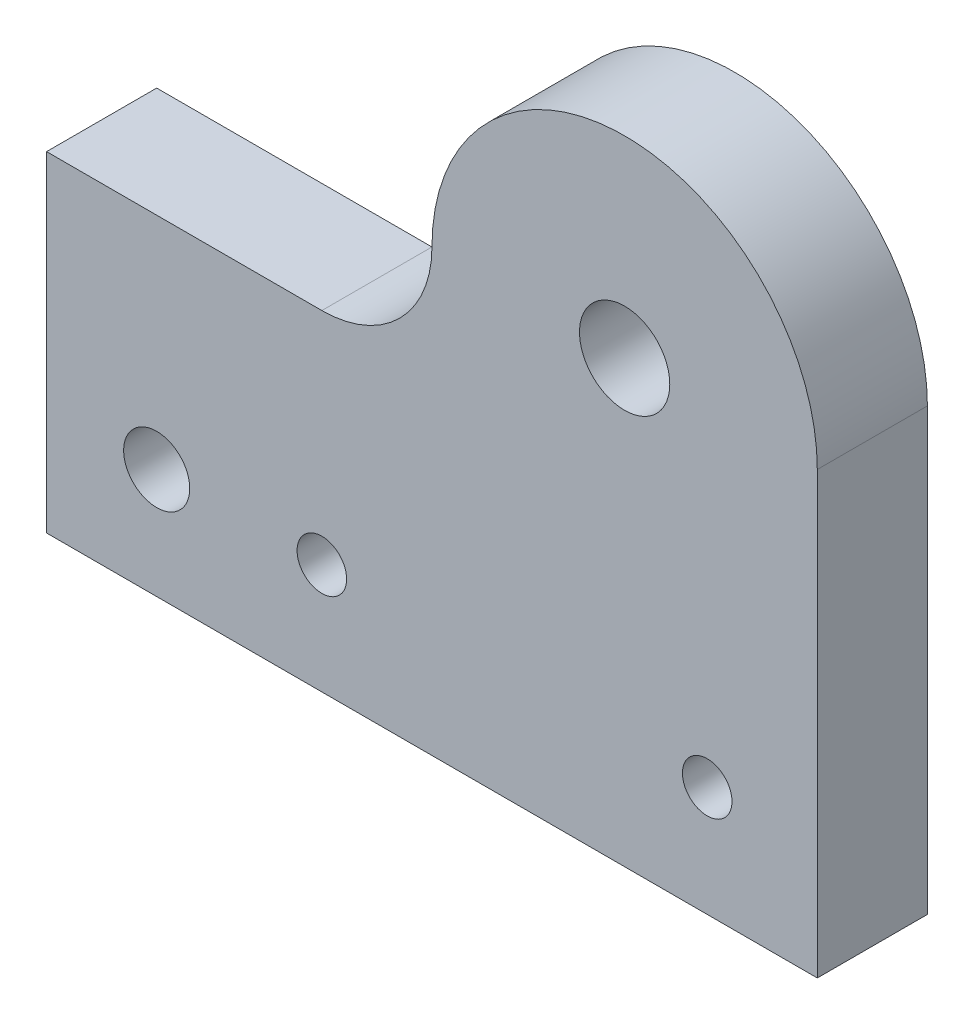
from build123d import *

# Parameters (mm, degrees)
SKETCH_2_R      = 4.1
SKETCH_2_R_2    = 3
SKETCH_2_R_3    = 2.25
EXTRUDE_1_DEPTH = 10


with BuildPart() as part:
    # 草图2 → 凸台-拉伸1 (new body)
    with BuildSketch(Plane.XY):
        with BuildLine():
            Line((-35, 15), (-10, 15))
            ThreePointArc((-10, 15), (-2.928932188, 17.928932188), (0, 25))
            ThreePointArc((0, 25), (17.5, 42.5), (35, 25))
            Line((35, 25), (35, 15))
            Line((35, 15), (35, -15))
            Line((35, -15), (-35, -15))
            Line((-35, -15), (-35, 15))
        make_face()
        with Locations((17.5, 25)):
            Circle(SKETCH_2_R, mode=Mode.SUBTRACT)
        with Locations((-25, -5)):
            Circle(SKETCH_2_R_2, mode=Mode.SUBTRACT)
        with Locations((-10, -5)):
            Circle(SKETCH_2_R_3, mode=Mode.SUBTRACT)
        with Locations((25, -5)):
            Circle(SKETCH_2_R_3, mode=Mode.SUBTRACT)
    extrude(amount=EXTRUDE_1_DEPTH)


solid = part.part
